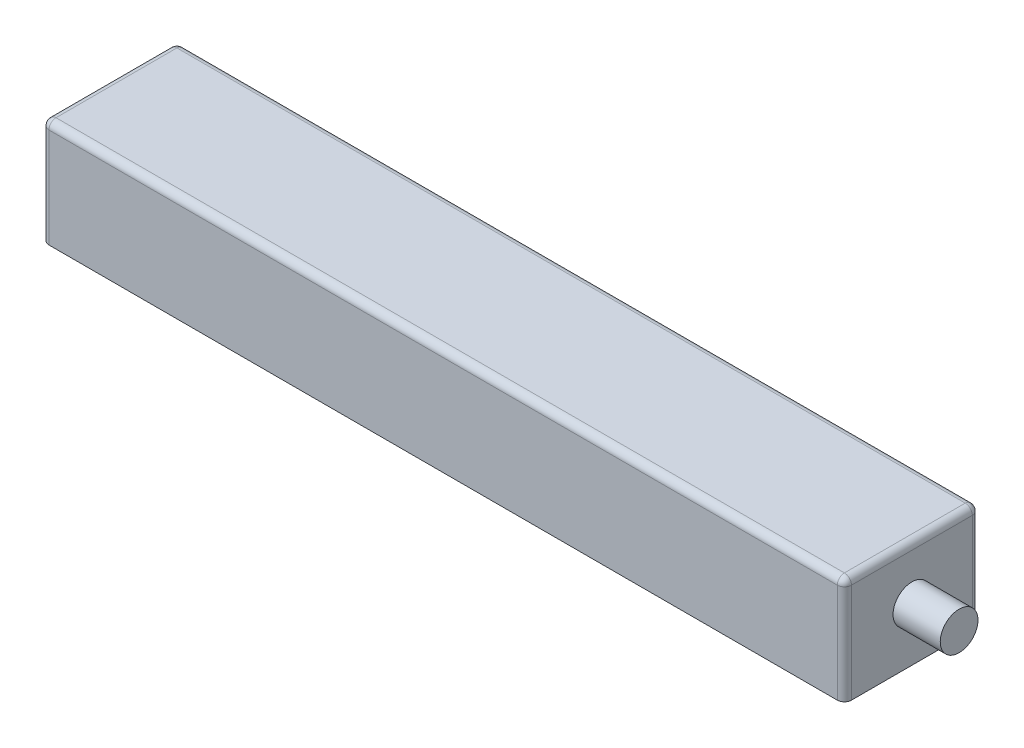
from build123d import *

# Parameters (mm, degrees)
SKETCH1_W           = 170
SKETCH1_H           = 28.6
BOSS_EXTRUDE1_DEPTH = 22.6
SKETCH2_R           = 4
BOSS_EXTRUDE2_DEPTH = 10
SKETCH3_R           = 4
BOSS_EXTRUDE3_DEPTH = 5
FILLET1_R           = 1.5


with BuildPart() as part:
    # Sketch1 → Boss-Extrude1 (new body)
    with BuildSketch(Plane(origin=(0, 0, 0), x_dir=(1, 0, 0), z_dir=(0, 1, 0))):
        Rectangle(SKETCH1_W, SKETCH1_H)
    extrude(amount=BOSS_EXTRUDE1_DEPTH)

    # Sketch2 → Boss-Extrude2 (add)
    with BuildSketch(Plane(origin=(85, 0, 0), x_dir=(0, 0, -1), z_dir=(1, 0, 0))):
        with Locations((0, 11.3)):
            Circle(SKETCH2_R)
    extrude(amount=BOSS_EXTRUDE2_DEPTH)

    # Sketch3 → Boss-Extrude3 (add)
    with BuildSketch(Plane.ZY.offset(85)):
        with Locations((0, 11.3)):
            Circle(SKETCH3_R)
    extrude(amount=BOSS_EXTRUDE3_DEPTH)

    # Fillet1
    fillet1_edges = [part.edges().sort_by_distance(p)[0] for p in [
        (85, 22.6, 0),
        (0, 22.6, -14.3),
        (-85, 22.6, 0),
        (0, 22.6, 14.3),
        (-85, 11.3, -14.3),
        (85, 11.3, -14.3),
        (85, 11.3, 14.3),
        (-85, 11.3, 14.3),
    ]]
    fillet(fillet1_edges, radius=FILLET1_R)


solid = part.part
